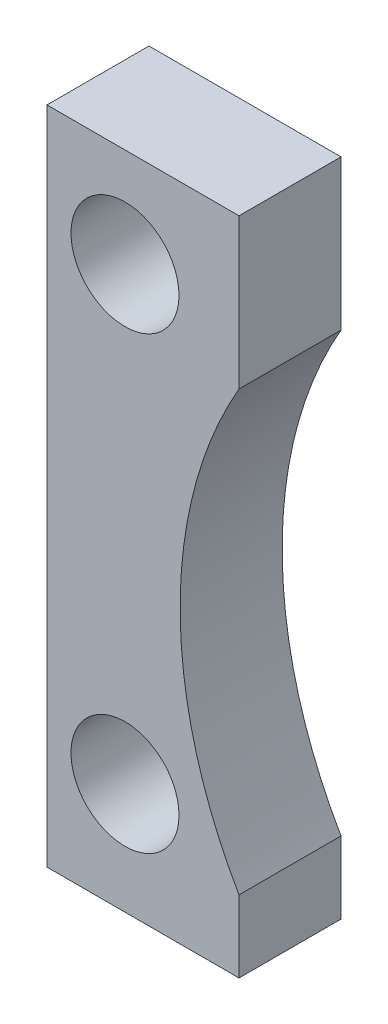
from build123d import *

# Parameters (mm, degrees)
Y_KSEKLIK_EKSTR_ZYON1_DEPTH = 8.5
IZIM2_R                     = 9
KES_EKSTR_ZYON1_DEPTH       = 18


with BuildPart() as part:
    # Çizim1 → Yükseklik-Ekstrüzyon1 (new body, symmetric)
    with BuildSketch(Plane.XY):
        with BuildLine():
            Line((0, 0), (0, 110))
            Line((0, 110), (32, 110))
            Line((32, 110), (32, 85))
            ThreePointArc((32, 85), (22.190316578, 48.5), (32, 12))
            Line((32, 12), (32, 0))
            Line((32, 0), (0, 0))
        make_face()
    extrude(amount=Y_KSEKLIK_EKSTR_ZYON1_DEPTH, both=True)

    # Çizim2 → Kes-Ekstrüzyon1 (cut, through all)
    with BuildSketch(Plane.XY.offset(8.5)):
        with Locations((13, 93.5)):
            Circle(IZIM2_R)
        with Locations((13, 18.5)):
            Circle(IZIM2_R)
    extrude(amount=-KES_EKSTR_ZYON1_DEPTH, mode=Mode.SUBTRACT)


solid = part.part
